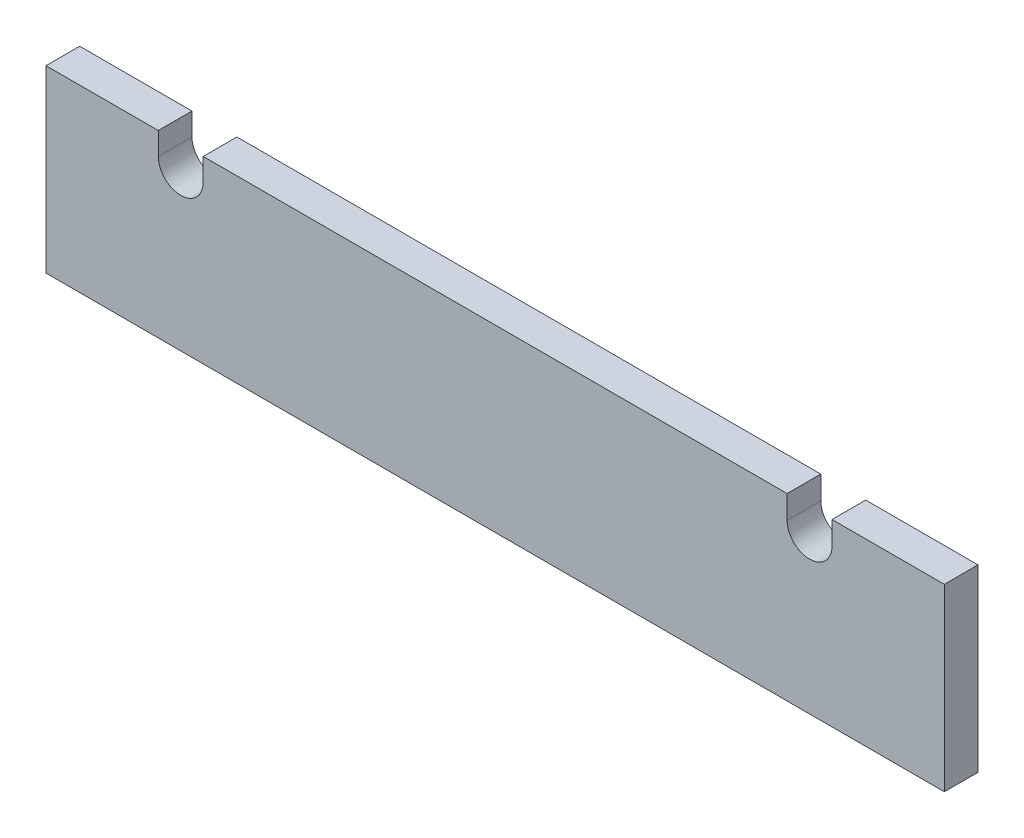
from build123d import *

# Parameters (mm, degrees)
BOSS_EXTRUDE1_DEPTH = 19.05


with BuildPart() as part:
    # Sketch1 → Boss-Extrude1 (new body)
    with BuildSketch(Plane.XY):
        with BuildLine():
            Line((0, 101.6), (0, 0))
            Line((0, 0), (508, 0))
            Line((508, 0), (508, 101.6))
            Line((508, 101.6), (444.5, 101.6))
            Line((444.5, 101.6), (444.5, 88.540005908))
            ThreePointArc((444.5, 88.540005908), (431.8, 75.840005908), (419.1, 88.540005908))
            Line((419.1, 88.540005908), (419.1, 101.6))
            Line((419.1, 101.6), (88.9, 101.6))
            Line((88.9, 101.6), (88.9, 88.9))
            ThreePointArc((88.9, 88.9), (76.2, 76.2), (63.5, 88.9))
            Line((63.5, 88.9), (63.5, 101.6))
            Line((63.5, 101.6), (0, 101.6))
        make_face()
    extrude(amount=BOSS_EXTRUDE1_DEPTH)


solid = part.part
